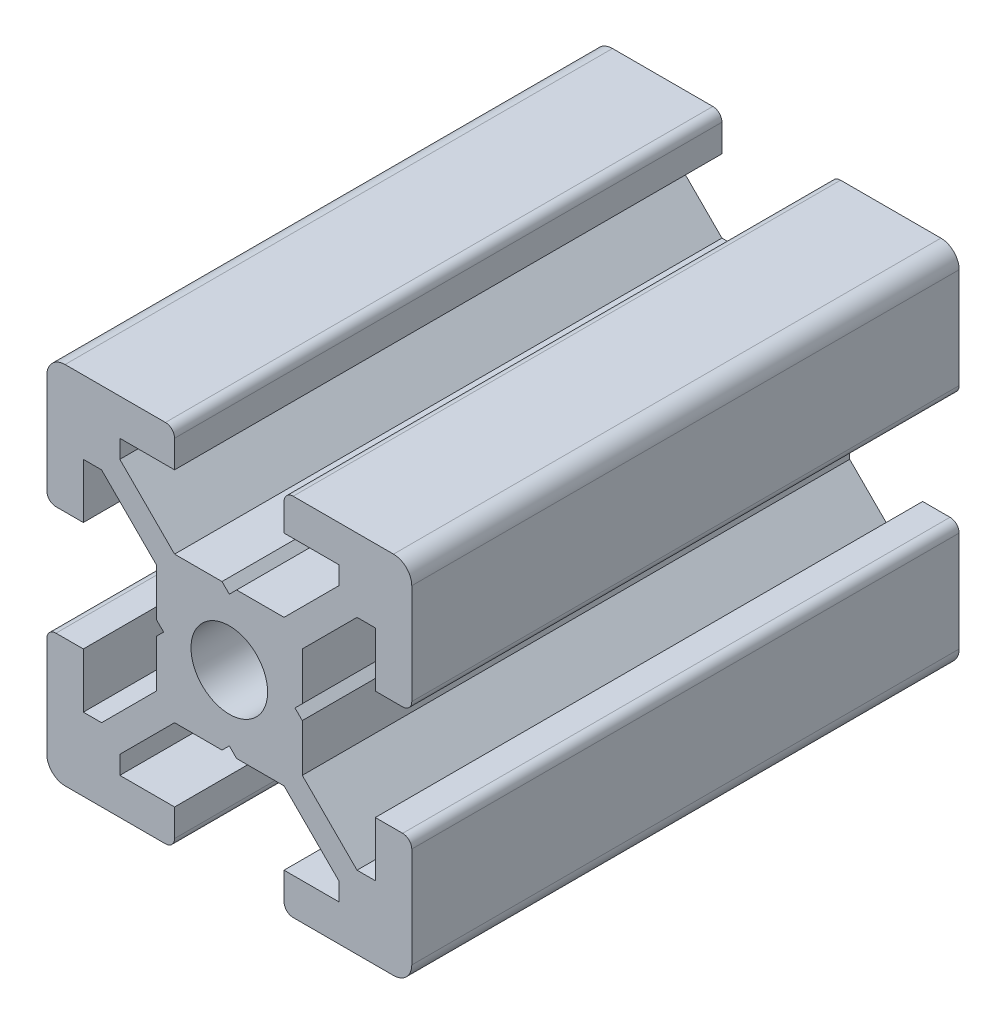
from build123d import *

# Parameters (mm, degrees)
SCHIZZO1_R                   = 2.1
ESTRUSIONE_ESTRUSIONE1_DEPTH = 30


with BuildPart() as part:
    # Schizzo1 → Estrusione-Estrusione1 (new body)
    with BuildSketch(Plane.XY):
        with BuildLine():
            Line((-3.6, 0), (-4, 0.4))
            Line((-4, 0.4), (-4, 3))
            Line((-4, 3), (-7, 6))
            Line((-7, 6), (-8, 6))
            Line((-8, 6), (-8, 3))
            Line((-8, 3), (-9.5, 3))
            ThreePointArc((-9.5, 3), (-9.853553391, 3.146446609), (-10, 3.5))
            Line((-10, 3.5), (-10, 9))
            ThreePointArc((-10, 9), (-9.707106781, 9.707106781), (-9, 10))
            Line((-9, 10), (-3.5, 10))
            ThreePointArc((-3.5, 10), (-3.146446609, 9.853553391), (-3, 9.5))
            Line((-3, 9.5), (-3, 8))
            Line((-3, 8), (-6, 8))
            Line((-6, 8), (-6, 7))
            Line((-6, 7), (-3, 4))
            Line((-3, 4), (-0.4, 4))
            Line((-0.4, 4), (0, 3.6))
            Line((0, 3.6), (0.4, 4))
            Line((0.4, 4), (3, 4))
            Line((3, 4), (6, 7))
            Line((6, 7), (6, 8))
            Line((6, 8), (3, 8))
            Line((3, 8), (3, 9.5))
            ThreePointArc((3, 9.5), (3.146446609, 9.853553391), (3.5, 10))
            Line((3.5, 10), (9, 10))
            ThreePointArc((9, 10), (9.707106781, 9.707106781), (10, 9))
            Line((10, 9), (10, 3.5))
            ThreePointArc((10, 3.5), (9.853553391, 3.146446609), (9.5, 3))
            Line((9.5, 3), (8, 3))
            Line((8, 3), (8, 6))
            Line((8, 6), (7, 6))
            Line((7, 6), (4, 3))
            Line((4, 3), (4, 0.4))
            Line((4, 0.4), (3.6, 0))
            Line((3.6, 0), (4, -0.4))
            Line((4, -0.4), (4, -3))
            Line((4, -3), (7, -6))
            Line((7, -6), (8, -6))
            Line((8, -6), (8, -3))
            Line((8, -3), (9.5, -3))
            ThreePointArc((9.5, -3), (9.853553391, -3.146446609), (10, -3.5))
            Line((10, -3.5), (10, -9))
            ThreePointArc((10, -9), (9.707106781, -9.707106781), (9, -10))
            Line((9, -10), (3.5, -10))
            ThreePointArc((3.5, -10), (3.146446609, -9.853553391), (3, -9.5))
            Line((3, -9.5), (3, -8))
            Line((3, -8), (6, -8))
            Line((6, -8), (6, -7))
            Line((6, -7), (3, -4))
            Line((3, -4), (0.4, -4))
            Line((0.4, -4), (0, -3.6))
            Line((0, -3.6), (-0.4, -4))
            Line((-0.4, -4), (-3, -4))
            Line((-3, -4), (-6, -7))
            Line((-6, -7), (-6, -8))
            Line((-6, -8), (-3, -8))
            Line((-3, -8), (-3, -9.5))
            ThreePointArc((-3, -9.5), (-3.146446609, -9.853553391), (-3.5, -10))
            Line((-3.5, -10), (-9, -10))
            ThreePointArc((-9, -10), (-9.707106781, -9.707106781), (-10, -9))
            Line((-10, -9), (-10, -3.5))
            ThreePointArc((-10, -3.5), (-9.853553391, -3.146446609), (-9.5, -3))
            Line((-9.5, -3), (-8, -3))
            Line((-8, -3), (-8, -6))
            Line((-8, -6), (-7, -6))
            Line((-7, -6), (-4, -3))
            Line((-4, -3), (-4, -0.4))
            Line((-4, -0.4), (-3.6, 0))
        make_face()
        Circle(SCHIZZO1_R, mode=Mode.SUBTRACT)
    extrude(amount=ESTRUSIONE_ESTRUSIONE1_DEPTH)


solid = part.part
